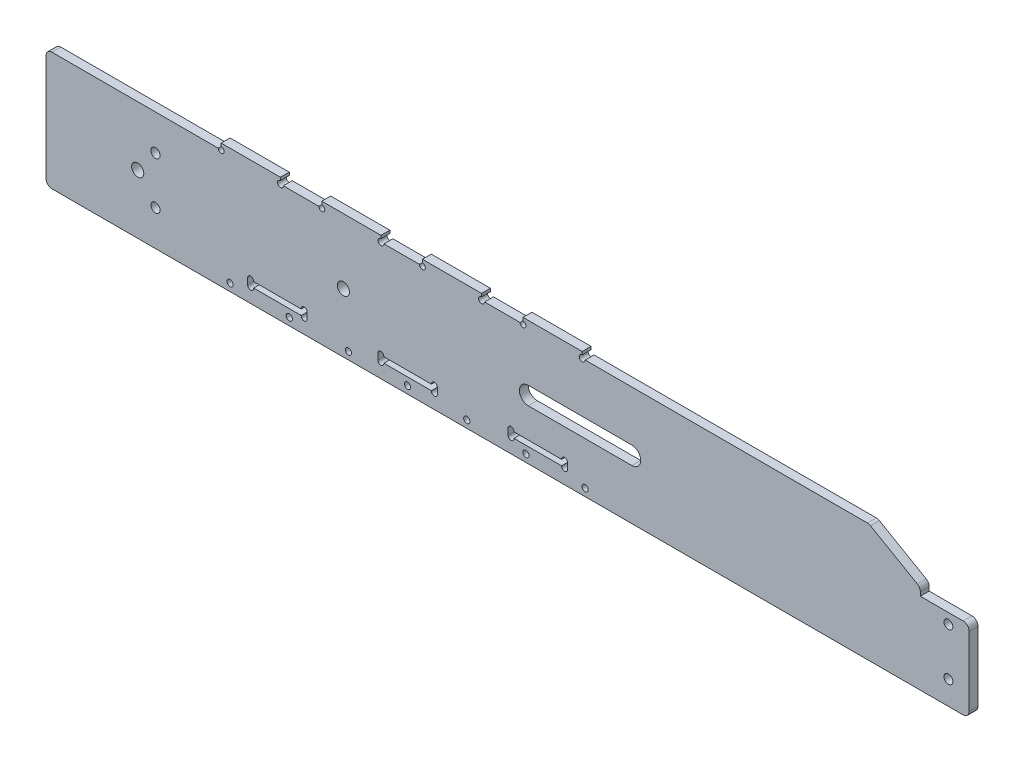
from build123d import *

# Parameters (mm, degrees)
SKETCH_1_W           = 360
SKETCH_1_H           = 40
EXTRUDE_1_DEPTH      = 3
SKETCH_2_W           = 16
SKETCH_2_H           = 27.5
EXTRUDE_2_DEPTH      = 3
SKETCH_3_R           = 1.5
SKETCH_3_R_2         = 4.5
SKETCH_3_R_3         = 3
CUT_EXTRUDE_1_DEPTH  = 4
SKETCH_6_W           = 0.5
SKETCH_6_H           = 12.5
CUT_EXTRUDE_4_DEPTH  = 10
CUT_EXTRUDE_10_DEPTH = 10
SKETCH_14_W          = 80
SKETCH_14_H          = 40
CUT_EXTRUDE_11_DEPTH = 10
SKETCH_15_R          = 2.05
CUT_EXTRUDE_12_DEPTH = 10
SKETCH_16_R          = 1.05
CUT_EXTRUDE_13_DEPTH = 10
SKETCH_17_W          = 20
SKETCH_17_H          = 2
EXTRUDE_3_DEPTH      = 3
SKETCH_18_W          = 20.1
SKETCH_18_H          = 2.1
CUT_EXTRUDE_14_DEPTH = 4
SKETCH_19_R          = 1
CUT_EXTRUDE_15_DEPTH = 3
CHAMFER_1_SIZE       = 10
CHAMFER_1_SIZE2      = 17.320508076
FILLET_2_R           = 2
SKETCH_22_R          = 1.55
CUT_EXTRUDE_17_DEPTH = 10
SKETCH_24_W          = 16.1
SKETCH_24_H          = 0.1
EXTRUDE_4_DEPTH      = 3
SKETCH_25_R          = 1
CUT_EXTRUDE_18_DEPTH = 10


with BuildPart() as part:
    # 草图1 → 凸台-拉伸1 (new body)
    with BuildSketch(Plane.XY):
        Rectangle(SKETCH_1_W, SKETCH_1_H)
    extrude(amount=EXTRUDE_1_DEPTH)

    # 草图2 → 凸台-拉伸2 (add)
    with BuildSketch(Plane.XY):
        with Locations((-188, -6.25)):
            Rectangle(SKETCH_2_W, SKETCH_2_H)
        with Locations((188, -6.25)):
            Rectangle(SKETCH_2_W, SKETCH_2_H)
    extrude(amount=EXTRUDE_2_DEPTH)

    # 草图3 → 切除-拉伸1 (cut, through all)
    with BuildSketch(Plane.XY.offset(3)):
        with Locations((-189, -12)):
            Circle(SKETCH_3_R)
        with Locations((-189, 4)):
            Circle(SKETCH_3_R)
        with Locations((-145, 0)):
            Circle(SKETCH_3_R_2)
        with Locations((189, 4)):
            Circle(SKETCH_3_R)
        with Locations((189, -12)):
            Circle(SKETCH_3_R)
        with Locations((72, 0)):
            Circle(SKETCH_3_R_3)
    extrude(amount=-CUT_EXTRUDE_1_DEPTH, mode=Mode.SUBTRACT)

    # 草图6 → 切除-拉伸4 (cut)
    with BuildSketch(Plane.XY.offset(3)):
        with Locations((-179.75, 13.75)):
            Rectangle(SKETCH_6_W, SKETCH_6_H)
        with Locations((179.75, 13.75)):
            Rectangle(SKETCH_6_W, SKETCH_6_H)
    extrude(amount=-CUT_EXTRUDE_4_DEPTH, mode=Mode.SUBTRACT)

    # 草图13 → 切除-拉伸10 (cut)
    with BuildSketch(Plane.XY.offset(3)):
        with BuildLine():
            Line((47, 3), (82, 3))
            ThreePointArc((82, 3), (85, 0), (82, -3))
            Line((82, -3), (47, -3))
            ThreePointArc((47, -3), (44, 0), (47, 3))
        make_face()
    extrude(amount=-CUT_EXTRUDE_10_DEPTH, mode=Mode.SUBTRACT)

    # 草图14 → 切除-拉伸11 (cut)
    with BuildSketch(Plane.XY.offset(3)):
        with Locations((-156, 0)):
            Rectangle(SKETCH_14_W, SKETCH_14_H)
    extrude(amount=-CUT_EXTRUDE_11_DEPTH, mode=Mode.SUBTRACT)

    # 草图15 → 切除-拉伸12 (cut)
    with BuildSketch(Plane.XY.offset(3)):
        with Locations((-85, 0)):
            Circle(SKETCH_15_R)
        with Locations((54, 0)):
            Circle(SKETCH_15_R)
        with Locations((-15.5, 0)):
            Circle(SKETCH_15_R)
    extrude(amount=-CUT_EXTRUDE_12_DEPTH, mode=Mode.SUBTRACT)

    # 草图16 → 切除-拉伸13 (cut)
    with BuildSketch(Plane(origin=(0, 0, 0), x_dir=(-1, 0, 0), z_dir=(0, 0, -1))):
        with Locations((-66.215, -17.5)):
            Circle(SKETCH_16_R)
        with Locations((-46.215, -17.5)):
            Circle(SKETCH_16_R)
        with Locations((-26.215, -17.5)):
            Circle(SKETCH_16_R)
        with Locations((-6.215, -17.5)):
            Circle(SKETCH_16_R)
        with Locations((13.785, -17.5)):
            Circle(SKETCH_16_R)
        with Locations((33.785, -17.5)):
            Circle(SKETCH_16_R)
        with Locations((53.785, -17.5)):
            Circle(SKETCH_16_R)
    extrude(amount=-CUT_EXTRUDE_13_DEPTH, mode=Mode.SUBTRACT)

    # 草图17 → 凸台-拉伸3 (add)
    with BuildSketch(Plane(origin=(0, 0, 0), x_dir=(-1, 0, 0), z_dir=(0, 0, -1))):
        with Locations((-55.215, 21)):
            Rectangle(SKETCH_17_W, SKETCH_17_H)
        with Locations((-21.215, 21)):
            Rectangle(SKETCH_17_W, SKETCH_17_H)
        with Locations((12.785, 21)):
            Rectangle(SKETCH_17_W, SKETCH_17_H)
        with Locations((46.785, 21)):
            Rectangle(SKETCH_17_W, SKETCH_17_H)
    extrude(amount=-EXTRUDE_3_DEPTH)

    # 草图18 → 切除-拉伸14 (cut, through all)
    with BuildSketch(Plane(origin=(0, 0, 0), x_dir=(-1, 0, 0), z_dir=(0, 0, -1))):
        with Locations((37.785, -14)):
            Rectangle(SKETCH_18_W, SKETCH_18_H)
        with Locations((-50.215, -14)):
            Rectangle(SKETCH_18_W, SKETCH_18_H)
        with Locations((-6.215, -14)):
            Rectangle(SKETCH_18_W, SKETCH_18_H)
    extrude(amount=-CUT_EXTRUDE_14_DEPTH, mode=Mode.SUBTRACT)

    # 草图19 → 切除-拉伸15 (cut)
    with BuildSketch(Plane(origin=(0, 0, 0), x_dir=(-1, 0, 0), z_dir=(0, 0, -1))):
        with Locations((-59.265, -12.95)):
            Circle(SKETCH_19_R)
        with Locations((-59.265, -15.05)):
            Circle(SKETCH_19_R)
        with Locations((-41.165, -12.95)):
            Circle(SKETCH_19_R)
        with Locations((-41.165, -15.05)):
            Circle(SKETCH_19_R)
        with Locations((-15.265, -12.95)):
            Circle(SKETCH_19_R)
        with Locations((-15.265, -15.05)):
            Circle(SKETCH_19_R)
        with Locations((2.835, -12.95)):
            Circle(SKETCH_19_R)
        with Locations((2.835, -15.05)):
            Circle(SKETCH_19_R)
        with Locations((28.735, -12.95)):
            Circle(SKETCH_19_R)
        with Locations((28.735, -15.05)):
            Circle(SKETCH_19_R)
        with Locations((46.835, -12.95)):
            Circle(SKETCH_19_R)
        with Locations((46.835, -15.05)):
            Circle(SKETCH_19_R)
    extrude(amount=-CUT_EXTRUDE_15_DEPTH, mode=Mode.SUBTRACT)

    # 倒角1
    chamfer_1_edges = [part.edges().sort_by_distance(p)[0] for p in [
        (179.5, 20, 1.5),
    ]]
    chamfer_1_side = [part.faces().sort_by_distance(p)[0] for p in [
        (179.5, 13.75, 1.5),
    ]]
    chamfer(chamfer_1_edges, length=CHAMFER_1_SIZE, length2=CHAMFER_1_SIZE2, reference=chamfer_1_side[0])

    # 圆角2
    fillet_2_edges = [part.edges().sort_by_distance(p)[0] for p in [
        (-116, 20, 1.5),
        (-116, -20, 1.5),
        (196, -20, 1.5),
        (196, 7.5, 1.5),
        (179.5, 10, 1.5),
        (162.179491924, 20, 1.5),
    ]]
    fillet(fillet_2_edges, radius=FILLET_2_R)

    # 草图22 → 切除-拉伸17 (cut)
    with BuildSketch(Plane(origin=(0, 0, 0), x_dir=(-1, 0, 0), z_dir=(0, 0, -1))):
        with Locations((79, 8)):
            Circle(SKETCH_22_R)
        with Locations((79, -8)):
            Circle(SKETCH_22_R)
    extrude(amount=-CUT_EXTRUDE_17_DEPTH, mode=Mode.SUBTRACT)

    # 草图24 → 凸台-拉伸4 (add)
    with BuildSketch(Plane(origin=(0, 0, 0), x_dir=(-1, 0, 0), z_dir=(0, 0, -1))):
        with Locations((-50.215, -13)):
            Rectangle(SKETCH_24_W, SKETCH_24_H)
        with Locations((-50.215, -15)):
            Rectangle(SKETCH_24_W, SKETCH_24_H)
        with Locations((-6.215, -13)):
            Rectangle(SKETCH_24_W, SKETCH_24_H)
        with Locations((-6.215, -15)):
            Rectangle(SKETCH_24_W, SKETCH_24_H)
        with Locations((37.785, -13)):
            Rectangle(SKETCH_24_W, SKETCH_24_H)
        with Locations((37.785, -15)):
            Rectangle(SKETCH_24_W, SKETCH_24_H)
    extrude(amount=-EXTRUDE_4_DEPTH)

    # 草图25 → 切除-拉伸18 (cut)
    with BuildSketch(Plane(origin=(0, 0, 0), x_dir=(-1, 0, 0), z_dir=(0, 0, -1))):
        with Locations((-65.215, 20)):
            Circle(SKETCH_25_R)
        with Locations((-45.215, 20)):
            Circle(SKETCH_25_R)
        with Locations((-31.215, 20)):
            Circle(SKETCH_25_R)
        with Locations((-11.215, 20)):
            Circle(SKETCH_25_R)
        with Locations((2.785, 20)):
            Circle(SKETCH_25_R)
        with Locations((22.785, 20)):
            Circle(SKETCH_25_R)
        with Locations((36.785, 20)):
            Circle(SKETCH_25_R)
        with Locations((56.785, 20)):
            Circle(SKETCH_25_R)
    extrude(amount=-CUT_EXTRUDE_18_DEPTH, mode=Mode.SUBTRACT)


solid = part.part
